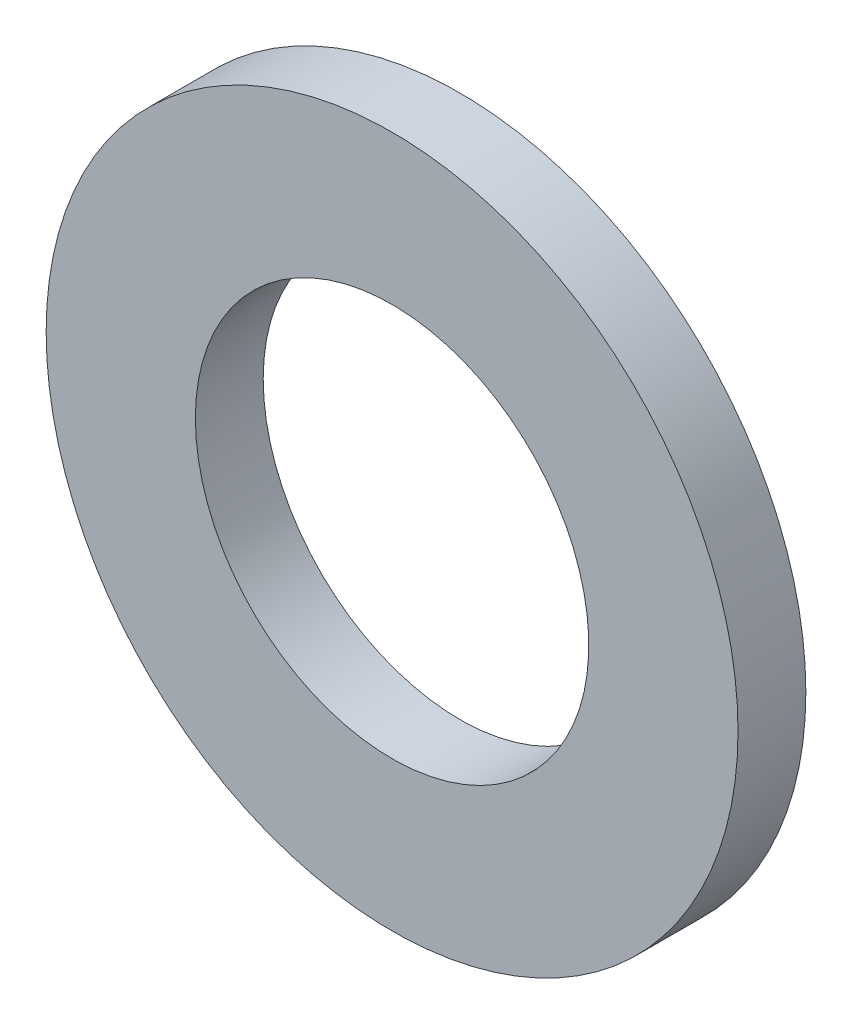
from build123d import *

# Parameters (mm, degrees)
SKETCH_1_W = 1.1
SKETCH_1_H = 0.5


with BuildPart() as part:
    # 草图1 → 旋转1 (revolve)
    with BuildSketch(Plane.XZ):
        with Locations((2, 0.25)):
            Rectangle(SKETCH_1_W, SKETCH_1_H)
    revolve(axis=Axis((0, 0, 0.5), (0, 0, -1)))


solid = part.part
